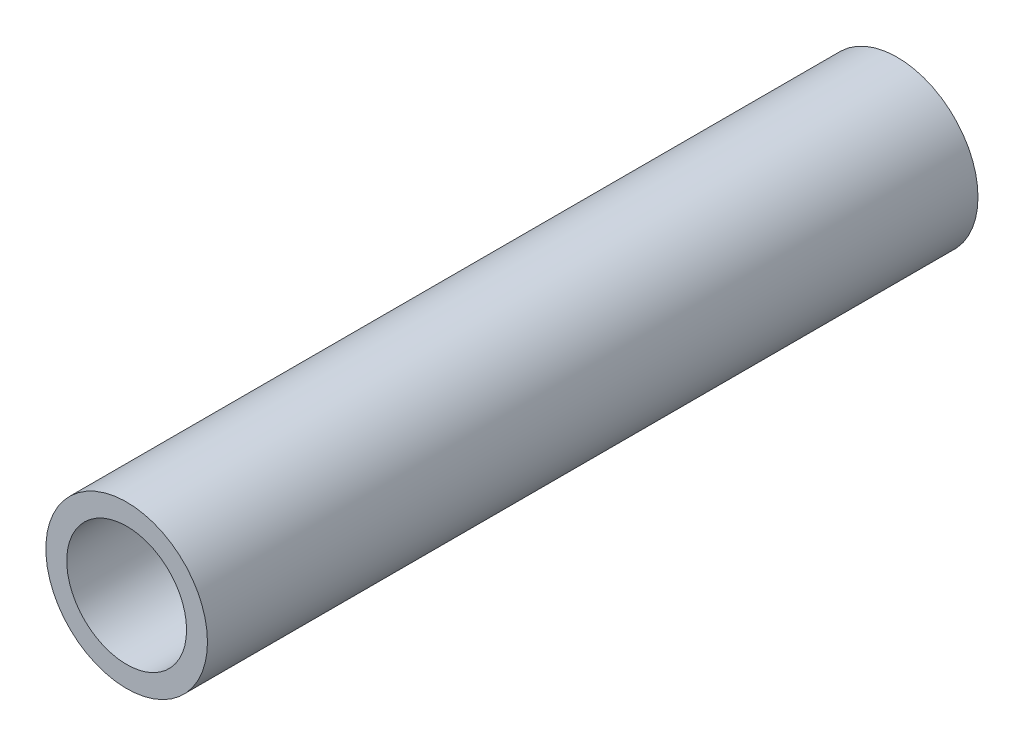
from build123d import *

# Parameters (mm, degrees)
SKETCH1_R           = 10.6553
SKETCH1_R_2         = 7.8994
BOSS_EXTRUDE1_DEPTH = 101.6


with BuildPart() as part:
    # Sketch1 → Boss-Extrude1 (new body)
    with BuildSketch(Plane.XY):
        Circle(SKETCH1_R)
        Circle(SKETCH1_R_2, mode=Mode.SUBTRACT)
    extrude(amount=BOSS_EXTRUDE1_DEPTH)


solid = part.part
